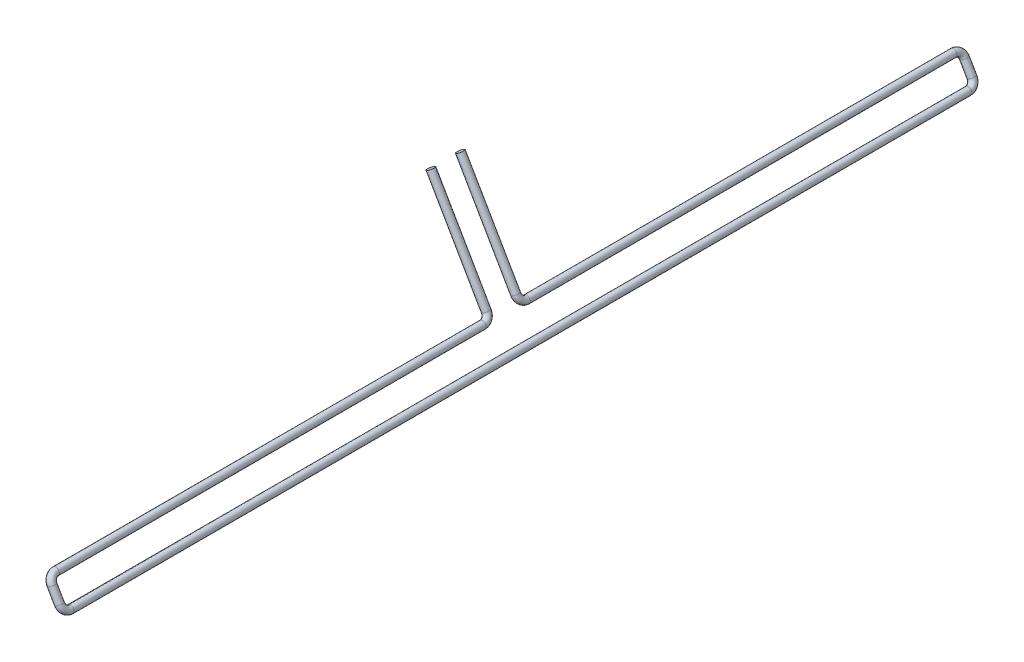
from build123d import *

# Parameters (mm, degrees)
SKETCH1_R = 0.75


with BuildPart() as part:
    # Sweep1: sweep along a path in Sketch2
    with BuildLine(Plane(origin=(25.024519053, 14.447912811, -100.982075021), x_dir=(0.5, -0.866025404, 0), z_dir=(-0.866025404, -0.5, 0))) as sweep1_path:
        Line((13.025079587, 100.982075021), (13.025079587, 192.502075021))
        ThreePointArc((13.025079587, 192.502075021), (12.585739759, 193.562735193), (11.525079587, 194.002075021))
        Line((11.525079587, 194.002075021), (8.517595341, 194.002075021))
        ThreePointArc((8.517595341, 194.002075021), (7.456935169, 193.562735193), (7.017595341, 192.502075021))
        Line((7.017595341, 192.502075021), (7.017595341, 105.482075021))
        ThreePointArc((7.017595341, 105.482075021), (6.578255513, 104.421414849), (5.517595341, 103.982075021))
        Line((5.517595341, 103.982075021), (-17.050460117, 103.982075021))
    # Sketch1 → Sweep1 (sweep)
    with BuildSketch(Plane.XY):
        with Locations((31.537058846, 3.167863003)):
            Circle(SKETCH1_R)
    sweep1 = sweep(path=sweep1_path.line)

    # Mirror1: Sweep1 across plane
    add(sweep1.mirror(Plane.XY))


solid = part.part
